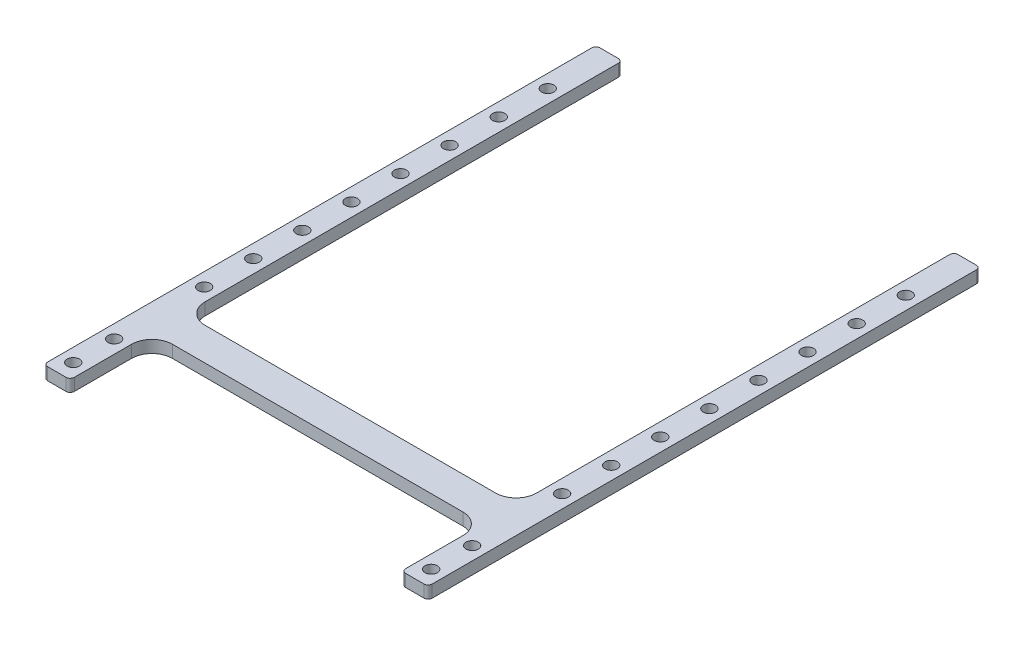
from build123d import *

# Parameters (mm, degrees)
BOSS_EXTRUDE1_DEPTH = 3
FILLET1_R           = 1
SKETCH2_R           = 1.5
CUT_EXTRUDE1_DEPTH  = 3


with BuildPart() as part:
    # Sketch1 → Boss-Extrude1 (new body)
    with BuildSketch(Plane(origin=(0, 0, 0), x_dir=(1, 0, 0), z_dir=(0, 1, 0))):
        with BuildLine():
            Line((-226.799741314, -52.674534602), (-233.299741314, -52.674534602))
            Line((-233.299741314, -52.674534602), (-233.299741314, 67.325465398))
            Line((-233.299741314, 67.325465398), (-233.299741314, 82.325465398))
            Line((-233.299741314, 82.325465398), (-226.799741314, 82.325465398))
            Line((-226.799741314, 82.325465398), (-226.799741314, 67.325465398))
            Line((-226.799741314, 67.325465398), (-226.799741314, -19.674534602))
            ThreePointArc((-226.799741314, -19.674534602), (-225.33527522, -23.210068508), (-221.799741314, -24.674534602))
            Line((-221.799741314, -24.674534602), (-150.799741314, -24.674534602))
            ThreePointArc((-150.799741314, -24.674534602), (-147.264207408, -23.210068508), (-145.799741314, -19.674534602))
            Line((-145.799741314, -19.674534602), (-145.799741314, 67.325465398))
            Line((-145.799741314, 67.325465398), (-145.799741314, 82.325465398))
            Line((-145.799741314, 82.325465398), (-139.299741314, 82.325465398))
            Line((-139.299741314, 82.325465398), (-139.299741314, 67.325465398))
            Line((-139.299741314, 67.325465398), (-139.299741314, -52.674534602))
            Line((-139.299741314, -52.674534602), (-145.799741314, -52.674534602))
            Line((-145.799741314, -52.674534602), (-145.799741314, -37.674534602))
            ThreePointArc((-145.799741314, -37.674534602), (-147.264207408, -34.139000697), (-150.799741314, -32.674534602))
            Line((-150.799741314, -32.674534602), (-221.799741314, -32.674534602))
            ThreePointArc((-221.799741314, -32.674534602), (-225.33527522, -34.139000697), (-226.799741314, -37.674534602))
            Line((-226.799741314, -37.674534602), (-226.799741314, -52.674534602))
        make_face()
    extrude(amount=BOSS_EXTRUDE1_DEPTH)

    # Fillet1
    fillet1_edges = [part.edges().sort_by_distance(p)[0] for p in [
        (-145.799741314, 1.5, -82.325465398),
        (-139.299741314, 1.5, -82.325465398),
        (-139.299741314, 1.5, 52.674534602),
        (-145.799741314, 1.5, 52.674534602),
        (-226.799741314, 1.5, 52.674534602),
        (-233.299741314, 1.5, 52.674534602),
        (-233.299741314, 1.5, -82.325465398),
        (-226.799741314, 1.5, -82.325465398),
    ]]
    fillet(fillet1_edges, radius=FILLET1_R)

    # Sketch2 → Cut-Extrude1 (cut)
    with BuildSketch(Plane(origin=(0, 3, 0), x_dir=(1, 0, 0), z_dir=(0, 1, 0))):
        with Locations((-230.049741314, 7.325465398)):
            Circle(SKETCH2_R)
        with Locations((-142.549741314, 7.325465398)):
            Circle(SKETCH2_R)
        with Locations((-230.049741314, 31.325465398)):
            Circle(SKETCH2_R)
        with Locations((-230.049741314, 55.325465398)):
            Circle(SKETCH2_R)
        with Locations((-230.049741314, 43.325465398)):
            Circle(SKETCH2_R)
        with Locations((-230.049741314, 19.325465398)):
            Circle(SKETCH2_R)
        with Locations((-230.049741314, -4.674534602)):
            Circle(SKETCH2_R)
        with Locations((-142.549741314, -4.674534602)):
            Circle(SKETCH2_R)
        with Locations((-230.049741314, -38.674534602)):
            Circle(SKETCH2_R)
        with Locations((-230.049741314, -48.674534602)):
            Circle(SKETCH2_R)
        with Locations((-142.549741314, -38.674534602)):
            Circle(SKETCH2_R)
        with Locations((-142.549741314, -48.674534602)):
            Circle(SKETCH2_R)
        with Locations((-142.549741314, 19.325465398)):
            Circle(SKETCH2_R)
        with Locations((-142.549741314, 31.325465398)):
            Circle(SKETCH2_R)
        with Locations((-142.549741314, 43.325465398)):
            Circle(SKETCH2_R)
        with Locations((-142.549741314, 55.325465398)):
            Circle(SKETCH2_R)
        with Locations((-230.049741314, -16.674534602)):
            Circle(SKETCH2_R)
        with Locations((-142.549741314, -16.674534602)):
            Circle(SKETCH2_R)
        with Locations((-230.049741314, 67.325465398)):
            Circle(SKETCH2_R)
        with Locations((-142.549741314, 67.325465398)):
            Circle(SKETCH2_R)
    extrude(amount=-CUT_EXTRUDE1_DEPTH, mode=Mode.SUBTRACT)


solid = part.part
